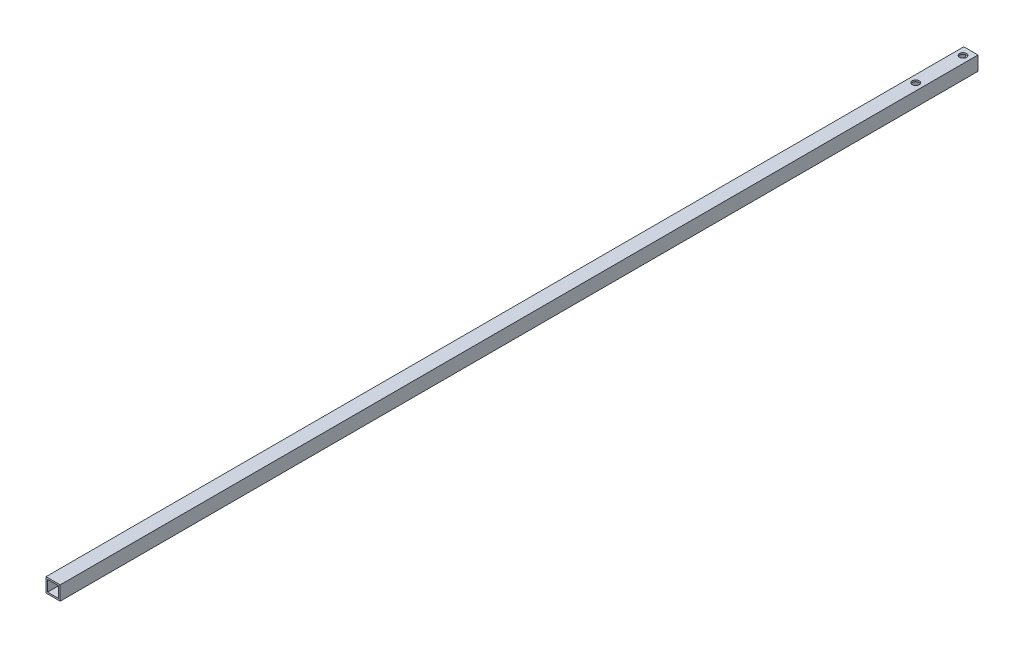
from build123d import *

# Parameters (mm, degrees)
SKETCH_1_W          = 9
SKETCH_1_H          = 9
EXTRUDE_1_DEPTH     = 582
SKETCH_2_W          = 7
SKETCH_2_H          = 7
CUT_EXTRUDE_1_DEPTH = 582
SKETCH_3_R          = 2.2
CUT_EXTRUDE_2_DEPTH = 582


with BuildPart() as part:
    # ｽｹｯﾁ1 → ﾎﾞｽ - 押し出し1 (new body)
    with BuildSketch(Plane.XY):
        Rectangle(SKETCH_1_W, SKETCH_1_H)
    extrude(amount=EXTRUDE_1_DEPTH)

    # ｽｹｯﾁ2 → ｶｯﾄ - 押し出し1 (cut)
    with BuildSketch(Plane.XY.offset(582)):
        Rectangle(SKETCH_2_W, SKETCH_2_H)
    extrude(amount=-CUT_EXTRUDE_1_DEPTH, mode=Mode.SUBTRACT)

    # ｽｹｯﾁ3 → ｶｯﾄ - 押し出し2 (cut)
    with BuildSketch(Plane(origin=(0, 4.5, 0), x_dir=(1, 0, 0), z_dir=(0, 1, 0))):
        with Locations((0, -5)):
            Circle(SKETCH_3_R)
        with Locations((0, -35)):
            Circle(SKETCH_3_R)
    extrude(amount=-CUT_EXTRUDE_2_DEPTH, mode=Mode.SUBTRACT)


solid = part.part
